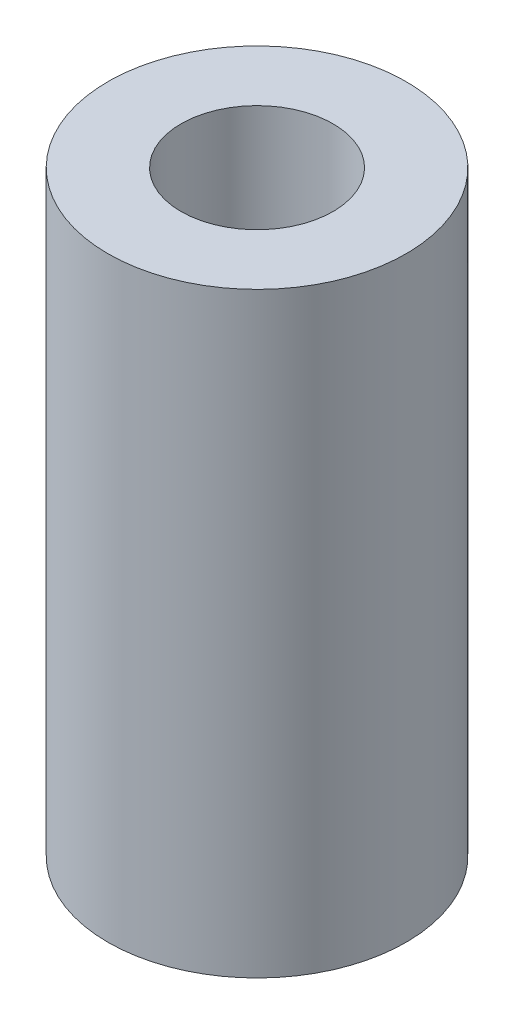
from build123d import *

# Parameters (mm, degrees)
SKETCH1_R           = 6.35
BOSS_EXTRUDE1_DEPTH = 25.4
SKETCH2_R           = 3.048
CUT_EXTRUDE1_DEPTH  = 8.636
SKETCH3_R           = 3.2385
CUT_EXTRUDE2_DEPTH  = 12.7


with BuildPart() as part:
    # Sketch1 → Boss-Extrude1 (new body)
    with BuildSketch(Plane(origin=(0, 0, 0), x_dir=(1, 0, 0), z_dir=(0, 1, 0))):
        Circle(SKETCH1_R)
    extrude(amount=BOSS_EXTRUDE1_DEPTH)

    # Sketch2 → Cut-Extrude1 (cut)
    with BuildSketch(Plane.XZ):
        Circle(SKETCH2_R)
    extrude(amount=-CUT_EXTRUDE1_DEPTH, mode=Mode.SUBTRACT)

    # Sketch3 → Cut-Extrude2 (cut)
    with BuildSketch(Plane(origin=(0, 25.4, 0), x_dir=(1, 0, 0), z_dir=(0, 1, 0))):
        Circle(SKETCH3_R)
    extrude(amount=-CUT_EXTRUDE2_DEPTH, mode=Mode.SUBTRACT)


solid = part.part
